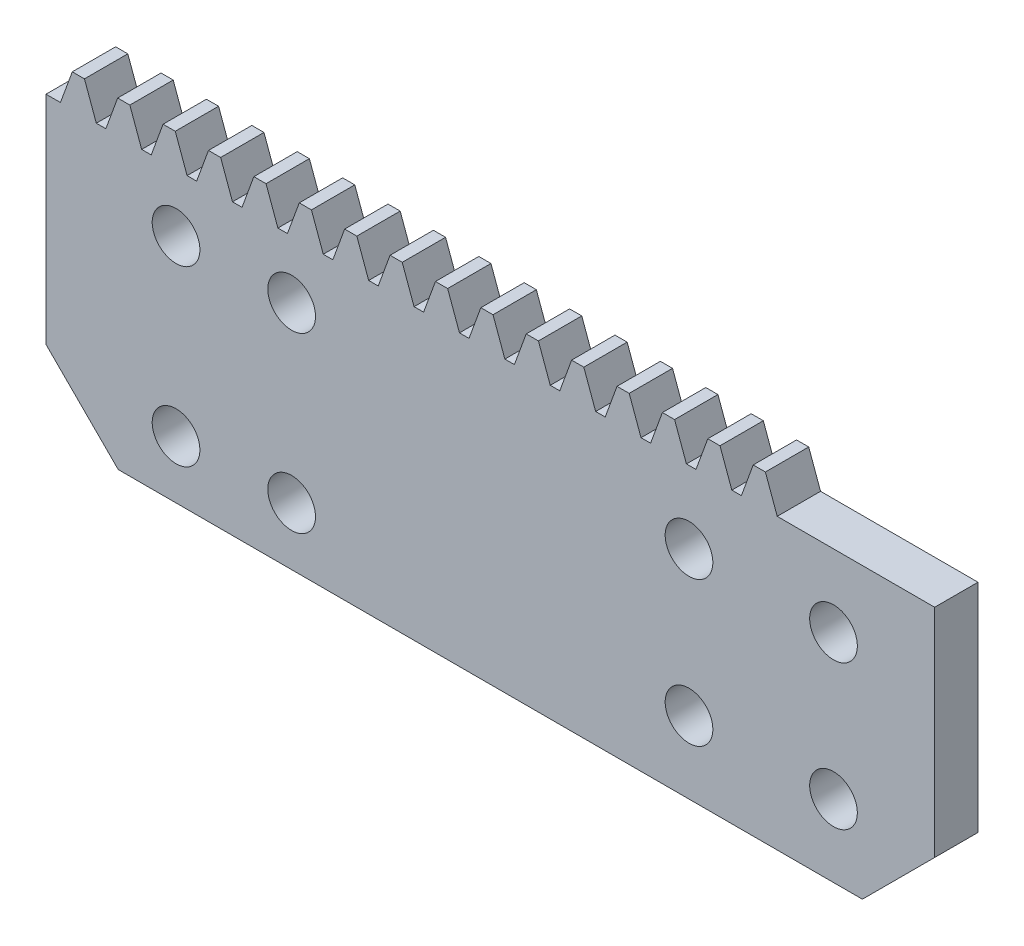
from build123d import *

# Parameters (mm, degrees)
SKETCH_1_W             = 61.5
SKETCH_1_H             = 20
EXTRUDE_1_DEPTH        = 3
EXTRUDE_2_DEPTH        = 3
PATTERN_LINEAR_1_COUNT = 16
PATTERN_LINEAR_1_PITCH = 3.141592654
CUT_EXTRUDE_1_REACH    = 5
SKETCH_3_R             = 1.65
CUT_EXTRUDE_2_REACH    = 5
SKETCH_4_R             = 1.65
CHAMFER_1_SIZE         = 5


with BuildPart() as part:
    # 草圖1 → 填料-伸長1 (new body)
    with BuildSketch(Plane.XY):
        Rectangle(SKETCH_1_W, SKETCH_1_H)
    extrude(amount=EXTRUDE_1_DEPTH)

    # 草圖2 → 填料-伸長2 (add)
    with BuildSketch(Plane.XY.offset(3)):
        Polygon((-29.75, 10), (-28.931066973, 12.25), (-28.088211111, 12.25), (-27.269278084, 10), align=None)
    extrude_2 = extrude(amount=-EXTRUDE_2_DEPTH)

    # 直線複製排列1: 填料-伸長2 ×16
    with Locations(*[(i * PATTERN_LINEAR_1_PITCH, 0, 0) for i in range(1, PATTERN_LINEAR_1_COUNT)]):
        add(extrude_2)

    # 草圖3 → 除料-伸長1 (cut, up to next)
    with BuildSketch(Plane.XY.offset(3), mode=Mode.PRIVATE) as cut_extrude_1_sk1:
        with Locations((-21.75, 6)):
            Circle(SKETCH_3_R)
    cut_extrude_1_tool1 = extrude(cut_extrude_1_sk1.sketch, amount=-CUT_EXTRUDE_1_REACH, mode=Mode.PRIVATE) & part.part
    add(cut_extrude_1_tool1.solids().sort_by_distance((-21.75, 6, 3))[0], mode=Mode.SUBTRACT)
    # 草圖3 → 除料-伸長1 (cut, up to next)
    with BuildSketch(Plane.XY.offset(3), mode=Mode.PRIVATE) as cut_extrude_1_sk2:
        with Locations((-13.75, 6)):
            Circle(SKETCH_3_R)
    cut_extrude_1_tool2 = extrude(cut_extrude_1_sk2.sketch, amount=-CUT_EXTRUDE_1_REACH, mode=Mode.PRIVATE) & part.part
    add(cut_extrude_1_tool2.solids().sort_by_distance((-13.75, 6, 3))[0], mode=Mode.SUBTRACT)
    # 草圖3 → 除料-伸長1 (cut, up to next)
    with BuildSketch(Plane.XY.offset(3), mode=Mode.PRIVATE) as cut_extrude_1_sk3:
        with Locations((-21.75, -6)):
            Circle(SKETCH_3_R)
    cut_extrude_1_tool3 = extrude(cut_extrude_1_sk3.sketch, amount=-CUT_EXTRUDE_1_REACH, mode=Mode.PRIVATE) & part.part
    add(cut_extrude_1_tool3.solids().sort_by_distance((-21.75, -6, 3))[0], mode=Mode.SUBTRACT)
    # 草圖3 → 除料-伸長1 (cut, up to next)
    with BuildSketch(Plane.XY.offset(3), mode=Mode.PRIVATE) as cut_extrude_1_sk4:
        with Locations((-13.75, -6)):
            Circle(SKETCH_3_R)
    cut_extrude_1_tool4 = extrude(cut_extrude_1_sk4.sketch, amount=-CUT_EXTRUDE_1_REACH, mode=Mode.PRIVATE) & part.part
    add(cut_extrude_1_tool4.solids().sort_by_distance((-13.75, -6, 3))[0], mode=Mode.SUBTRACT)

    # 草圖4 → 除料-伸長2 (cut, up to next)
    with BuildSketch(Plane.XY.offset(3), mode=Mode.PRIVATE) as cut_extrude_2_sk1:
        with Locations((23.75, 5)):
            Circle(SKETCH_4_R)
    cut_extrude_2_tool1 = extrude(cut_extrude_2_sk1.sketch, amount=-CUT_EXTRUDE_2_REACH, mode=Mode.PRIVATE) & part.part
    add(cut_extrude_2_tool1.solids().sort_by_distance((23.75, 5, 3))[0], mode=Mode.SUBTRACT)
    # 草圖4 → 除料-伸長2 (cut, up to next)
    with BuildSketch(Plane.XY.offset(3), mode=Mode.PRIVATE) as cut_extrude_2_sk2:
        with Locations((13.75, 5)):
            Circle(SKETCH_4_R)
    cut_extrude_2_tool2 = extrude(cut_extrude_2_sk2.sketch, amount=-CUT_EXTRUDE_2_REACH, mode=Mode.PRIVATE) & part.part
    add(cut_extrude_2_tool2.solids().sort_by_distance((13.75, 5, 3))[0], mode=Mode.SUBTRACT)
    # 草圖4 → 除料-伸長2 (cut, up to next)
    with BuildSketch(Plane.XY.offset(3), mode=Mode.PRIVATE) as cut_extrude_2_sk3:
        with Locations((23.75, -5)):
            Circle(SKETCH_4_R)
    cut_extrude_2_tool3 = extrude(cut_extrude_2_sk3.sketch, amount=-CUT_EXTRUDE_2_REACH, mode=Mode.PRIVATE) & part.part
    add(cut_extrude_2_tool3.solids().sort_by_distance((23.75, -5, 3))[0], mode=Mode.SUBTRACT)
    # 草圖4 → 除料-伸長2 (cut, up to next)
    with BuildSketch(Plane.XY.offset(3), mode=Mode.PRIVATE) as cut_extrude_2_sk4:
        with Locations((13.75, -5)):
            Circle(SKETCH_4_R)
    cut_extrude_2_tool4 = extrude(cut_extrude_2_sk4.sketch, amount=-CUT_EXTRUDE_2_REACH, mode=Mode.PRIVATE) & part.part
    add(cut_extrude_2_tool4.solids().sort_by_distance((13.75, -5, 3))[0], mode=Mode.SUBTRACT)

    # 導角1
    chamfer_1_edges = [part.edges().sort_by_distance(p)[0] for p in [
        (30.75, -10, 1.5),
        (-30.75, -10, 1.5),
    ]]
    chamfer(chamfer_1_edges, length=CHAMFER_1_SIZE)


solid = part.part
